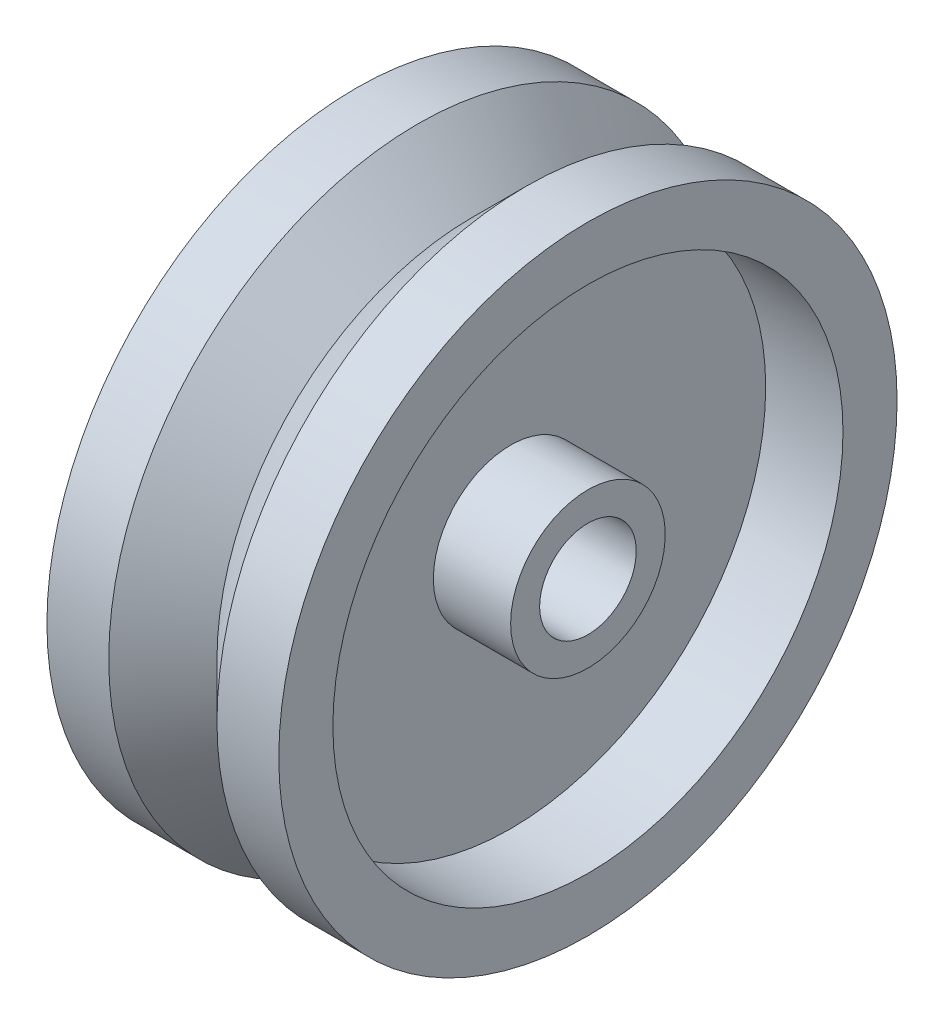
from build123d import *


with BuildPart() as part:
    # Sketch2 → Revolve1 (revolve)
    with BuildSketch(Plane(origin=(0, 0, 0), x_dir=(1, 0, 0), z_dir=(0, 1, 0))):
        Polygon((0, -6.47515528), (15, -6.47515528), (15, -8.35015528), (10, -8.35015528), (10, -19.85015528), (15, -19.85015528), (15, -23.35015528), (11, -23.35015528), (7.5, -19.85015528), (4, -23.35015528), (0, -23.35015528), (0, -19.85015528), (5, -19.85015528), (5, -8.35015528), (0, -8.35015528), align=None)
    revolve(axis=Axis((-0.838509317, 0, 3.35015528), (1, 0, 0)))


solid = part.part
